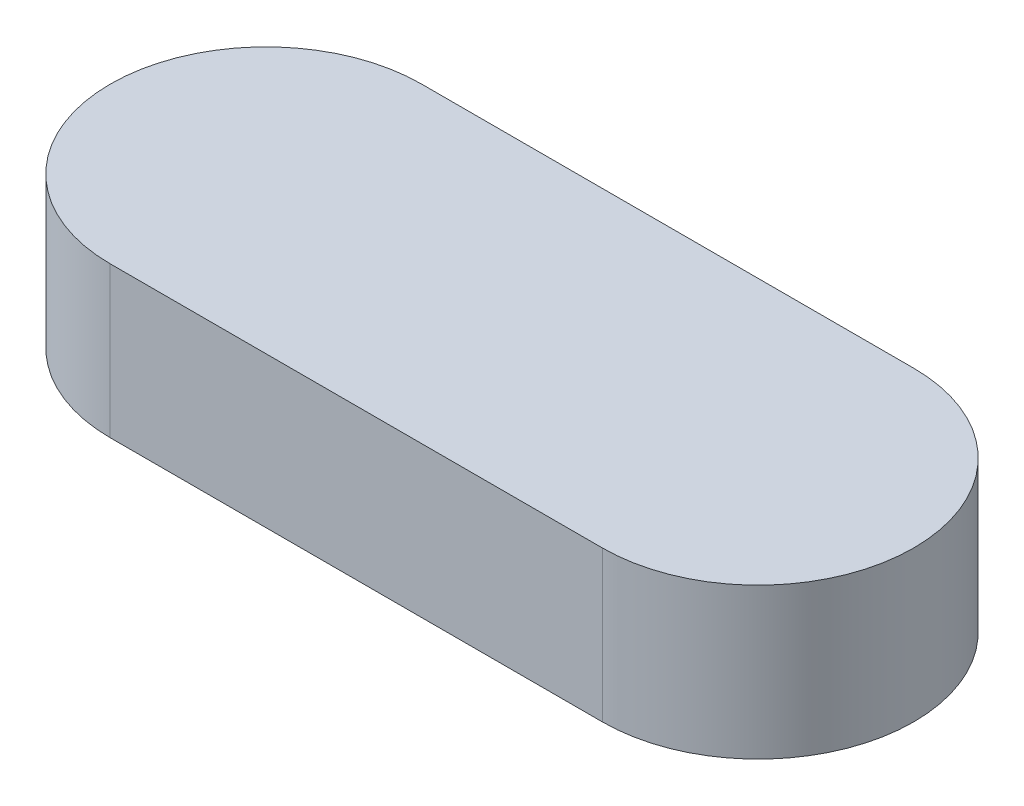
from build123d import *

# Parameters (mm, degrees)
BOSS_EXTRUDE1_DEPTH = 7.5


with BuildPart() as part:
    # Sketch1 → Boss-Extrude1 (new body)
    with BuildSketch(Plane(origin=(0, 0, 0), x_dir=(1, 0, 0), z_dir=(0, 1, 0))):
        with BuildLine():
            Line((-12.25, 7.75), (12.25, 7.75))
            ThreePointArc((12.25, 7.75), (20, 0), (12.25, -7.75))
            Line((12.25, -7.75), (-12.25, -7.75))
            ThreePointArc((-12.25, -7.75), (-20, 0), (-12.25, 7.75))
        make_face()
    extrude(amount=BOSS_EXTRUDE1_DEPTH)


solid = part.part
